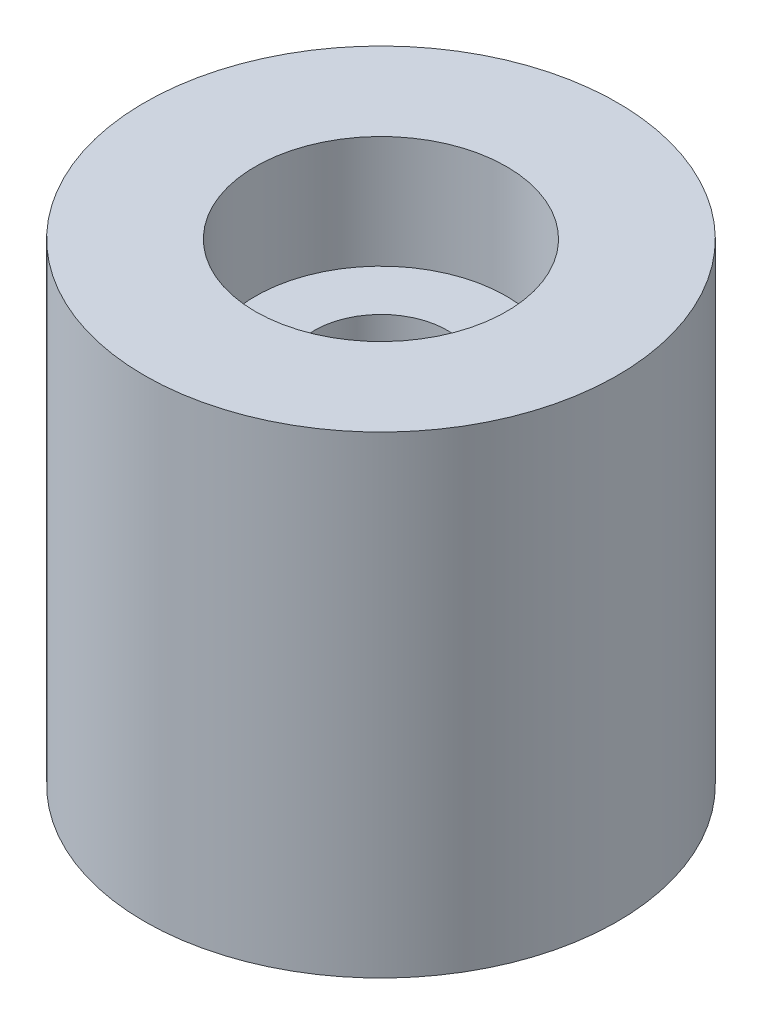
from build123d import *

# Parameters (mm, degrees)
SKETCH1_R           = 8
SKETCH1_R_2         = 2.25
BOSS_EXTRUDE1_DEPTH = 16
SKETCH2_R           = 4.25
CUT_EXTRUDE1_DEPTH  = 3.8


with BuildPart() as part:
    # Sketch1 → Boss-Extrude1 (new body)
    with BuildSketch(Plane(origin=(0, 0, 0), x_dir=(1, 0, 0), z_dir=(0, 1, 0))):
        Circle(SKETCH1_R)
        Circle(SKETCH1_R_2, mode=Mode.SUBTRACT)
    extrude(amount=BOSS_EXTRUDE1_DEPTH)

    # Sketch2 → Cut-Extrude1 (cut)
    with BuildSketch(Plane(origin=(0, 16, 0), x_dir=(1, 0, 0), z_dir=(0, 1, 0))):
        Circle(SKETCH2_R)
    extrude(amount=-CUT_EXTRUDE1_DEPTH, mode=Mode.SUBTRACT)


solid = part.part
